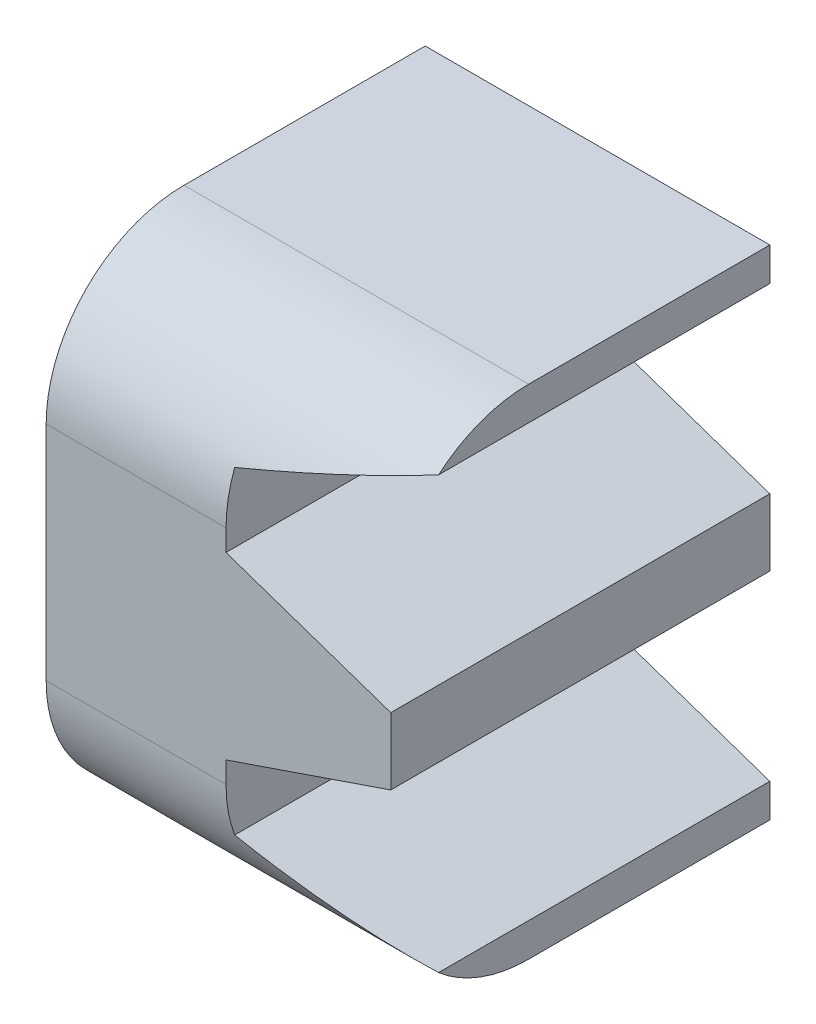
from build123d import *

# Parameters (mm, degrees)
BOSS_EXTRUDE1_DEPTH = 5.5
FILLET1_R           = 2


with BuildPart() as part:
    # Sketch1 → Boss-Extrude1 (new body)
    with BuildSketch(Plane.XY):
        Polygon((2.754977626, -3.612882911), (2.754977626, -3.127020625), (0.364622857, -2.309471144), (0.364622857, -1.303411767), (2.754977626, -0.485862286), (2.754977626, 0.485862286), (0.364622857, 1.303411767), (0.364622857, 2.309471144), (2.754977626, 3.127020625), (2.754977626, 3.612882911), (-2.245021882, 3.612882911), (-2.245021014, -3.612882911), align=None)
    extrude(amount=BOSS_EXTRUDE1_DEPTH)

    # Fillet1
    fillet1_edges = [part.edges().sort_by_distance(p)[0] for p in [
        (0.254978306, -3.612882911, 5.5),
        (0.254977872, 3.612882911, 5.5),
    ]]
    fillet(fillet1_edges, radius=FILLET1_R)


solid = part.part
